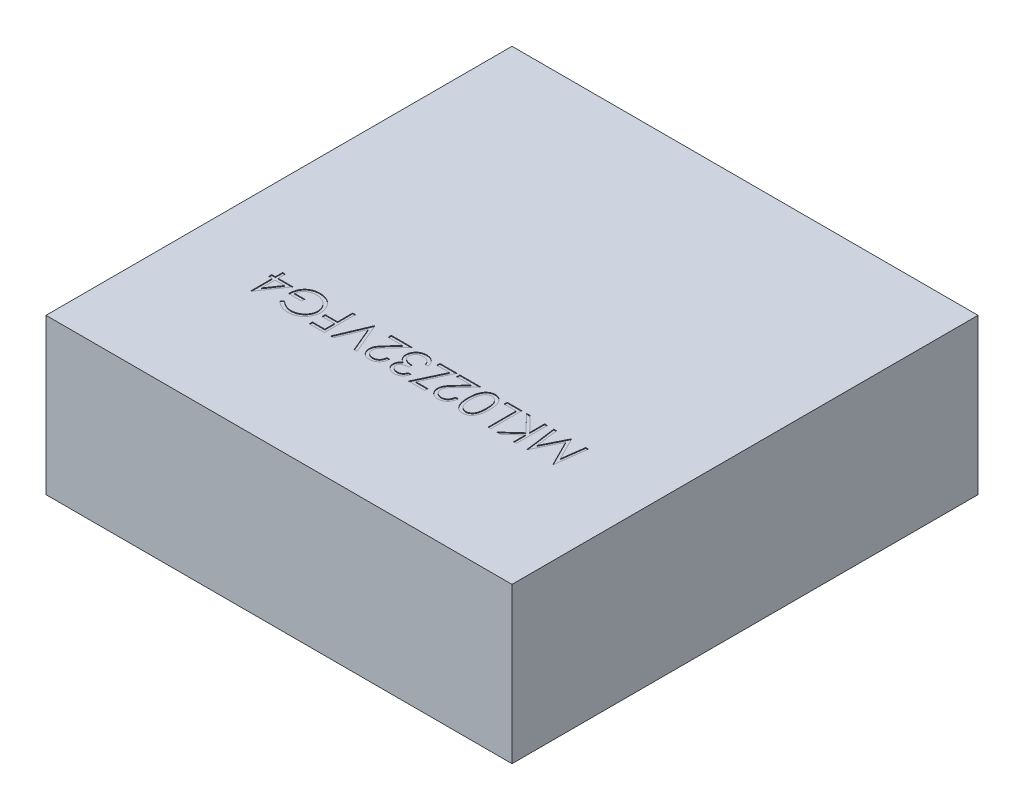
from build123d import *

# Parameters (mm, degrees)
BASES_W          = 3
BASES_H          = 3
BASE_DEPTH       = 1
PARTNUMBER_DEPTH = 0.005


with BuildPart() as part:
    # BaseS → Base (new body)
    with BuildSketch(Plane(origin=(0, 0, 0), x_dir=(1, 0, 0), z_dir=(0, 1, 0))):
        Rectangle(BASES_W, BASES_H)
    extrude(amount=BASE_DEPTH)

    # PartNumberS → PartNumber (cut)
    with BuildSketch(Plane(origin=(0, 1, 0), x_dir=(1, 0, 0), z_dir=(0, 1, 0))):
        Polygon((0.992307692, -0.5), (0.965905449, -0.7), (0.963341346, -0.7), (0.880769231, -0.535897436), (0.798397436, -0.7), (0.795793269, -0.7), (0.769230769, -0.5), (0.787259615, -0.5), (0.806410256, -0.643910256), (0.878605769, -0.5), (0.882652244, -0.5), (0.955128205, -0.644230769), (0.974238782, -0.5), align=None)
        Polygon((0.728205128, -0.7), (0.71025641, -0.7), (0.71025641, -0.623838141), (0.626883013, -0.7), (0.601282051, -0.7), (0.699559295, -0.61025641), (0.593589744, -0.5), (0.617508013, -0.5), (0.71025641, -0.596514423), (0.71025641, -0.5), (0.728205128, -0.5), align=None)
        Polygon((0.564102564, -0.7), (0.546153846, -0.7), (0.546153846, -0.520512821), (0.469230769, -0.520512821), (0.469230769, -0.5), (0.564102564, -0.5), align=None)
        with BuildLine():
            add(Edge.make_bspline(
                [(0.453846154, -0.599919872), (0.45382741, -0.603125437), (0.453791, -0.609352293), (0.453385947, -0.618425701), (0.45271307, -0.626937718), (0.451790935, -0.63488875), (0.450668765, -0.642280851), (0.449170735, -0.649094264), (0.447467153, -0.655360534), (0.445492704, -0.661100057), (0.443264911, -0.666390288), (0.440839812, -0.671328601), (0.438122833, -0.675909097), (0.4352634, -0.680199264), (0.432161436, -0.684155927), (0.42882773, -0.687761304), (0.425291645, -0.691071266), (0.421536448, -0.694031384), (0.417597932, -0.696610732), (0.413592604, -0.698948853), (0.409406222, -0.700798371), (0.405142046, -0.702379922), (0.400765722, -0.703632724), (0.396275342, -0.704504146), (0.391666876, -0.705049326), (0.388556562, -0.705101663), (0.386979167, -0.705128205)],
                knots=[0, 0, 0, 0, 1.64625301, 3.197870201, 4.6634513, 6.030635694, 7.308242971, 8.501545196, 9.611429483, 10.641742253, 11.616230371, 12.55791849, 13.464870342, 14.34944951, 15.20427819, 16.044004467, 16.869007726, 17.689551165, 18.496129964, 19.285613293, 20.0683943, 20.843080271, 21.620342827, 22.403213977, 23.190190624, 24, 24, 24, 24], degree=3))
            add(Edge.make_bspline(
                [(0.386979167, -0.705128205), (0.385387797, -0.705106134), (0.38222153, -0.705062219), (0.377557236, -0.704444098), (0.372974186, -0.703646272), (0.368541914, -0.702366689), (0.364176614, -0.700835502), (0.359986842, -0.698815126), (0.355824678, -0.696617809), (0.351879203, -0.693937268), (0.348032533, -0.690974829), (0.344426682, -0.687611703), (0.340969474, -0.683940966), (0.337791486, -0.679880749), (0.334756515, -0.675493306), (0.331979772, -0.67074186), (0.329403504, -0.66563694), (0.326979285, -0.66020221), (0.32485937, -0.654292502), (0.322974596, -0.647944676), (0.321429704, -0.641101249), (0.320152106, -0.633800343), (0.319160447, -0.62600579), (0.318438734, -0.617733383), (0.318057372, -0.608977945), (0.317985566, -0.60299178), (0.317948718, -0.599919872)],
                knots=[0, 0, 0, 0, 0.810910589, 1.61342667, 2.396193133, 3.181089899, 3.963115317, 4.752255436, 5.550715454, 6.36105385, 7.181178335, 8.024612154, 8.872680183, 9.750181803, 10.651284446, 11.591556747, 12.554036451, 13.566402641, 14.62422919, 15.753422176, 16.94128843, 18.199818041, 19.531985927, 20.947085226, 22.433341622, 24, 24, 24, 24], degree=3))
            add(Edge.make_bspline(
                [(0.317948718, -0.599919872), (0.317986423, -0.596861401), (0.318060053, -0.590888756), (0.318430055, -0.582172145), (0.319179794, -0.573944878), (0.32009359, -0.566195034), (0.321411105, -0.558932745), (0.322877893, -0.552119008), (0.324748864, -0.545817847), (0.326818495, -0.539958796), (0.329208983, -0.534547089), (0.331765848, -0.529463239), (0.334584042, -0.524738759), (0.337560777, -0.520323507), (0.34079893, -0.516298111), (0.344209352, -0.512586312), (0.347850186, -0.509217343), (0.351716657, -0.506219926), (0.355699424, -0.503519192), (0.3598624, -0.501243526), (0.364108132, -0.49925961), (0.368480783, -0.497664773), (0.372952469, -0.496404048), (0.377539293, -0.495545817), (0.382222154, -0.494940871), (0.385388005, -0.4948949), (0.386979167, -0.494871795)],
                knots=[0, 0, 0, 0, 1.561431216, 3.049195289, 4.452146966, 5.778046447, 7.031138842, 8.218704273, 9.334037798, 10.384210803, 11.388620812, 12.352076869, 13.287433199, 14.19507451, 15.06813243, 15.922055533, 16.766344942, 17.596869952, 18.417486629, 19.220035357, 20.016159057, 20.807716045, 21.59340902, 22.384936649, 23.188266813, 24, 24, 24, 24], degree=3))
            add(Edge.make_bspline(
                [(0.386979167, -0.494871795), (0.388556507, -0.494898572), (0.391666713, -0.494951373), (0.396275972, -0.495493155), (0.400759842, -0.49637662), (0.405127285, -0.497576361), (0.409387239, -0.49910116), (0.413497978, -0.501040647), (0.417513774, -0.503290158), (0.421416363, -0.505849366), (0.425131138, -0.508782275), (0.428680244, -0.512025516), (0.431970786, -0.515662669), (0.435051357, -0.519635684), (0.437934516, -0.52393665), (0.440639989, -0.528552213), (0.443057704, -0.533538633), (0.445336009, -0.538857583), (0.447344353, -0.544639279), (0.449098001, -0.550927022), (0.450576487, -0.557763701), (0.451754121, -0.565149643), (0.452718866, -0.573073415), (0.453385284, -0.581547642), (0.453790797, -0.590554174), (0.453827365, -0.596741003), (0.453846154, -0.599919872)],
                knots=[0, 0, 0, 0, 0.810976328, 1.599087026, 2.383086309, 3.159618043, 3.926613167, 4.707144544, 5.494386734, 6.292609454, 7.104690378, 7.92621526, 8.762510248, 9.62398222, 10.509836085, 11.424023232, 12.373226806, 13.358118208, 14.398657954, 15.5185989, 16.713620699, 17.994156382, 19.364120462, 20.818119981, 22.365111093, 24, 24, 24, 24], degree=3))
        make_face()
        with BuildLine():
            add(Edge.make_bspline(
                [(0.435897436, -0.6), (0.435890461, -0.597328656), (0.435876923, -0.592144103), (0.4355335, -0.58462337), (0.43505549, -0.577596997), (0.434454125, -0.571067726), (0.433553497, -0.565058375), (0.432531677, -0.559543965), (0.431306074, -0.554534693), (0.42984879, -0.549986815), (0.428188889, -0.54583583), (0.426379449, -0.541971444), (0.424419435, -0.538346652), (0.422263877, -0.534974532), (0.419881894, -0.531873918), (0.417326651, -0.529030085), (0.414583291, -0.526454611), (0.410786486, -0.523398046), (0.40579838, -0.520202297), (0.399481442, -0.517453649), (0.392987642, -0.515715134), (0.388578797, -0.515494661), (0.386378205, -0.515384615)],
                knots=[0, 0, 0, 0, 1.459193451, 2.832007961, 4.111736495, 5.306635028, 6.412683014, 7.430020708, 8.369596877, 9.227877302, 10.036669781, 10.810175692, 11.557788084, 12.286326232, 12.994037279, 13.69140682, 14.37267704, 15.047194847, 16.352618509, 17.594157723, 18.799169539, 20, 20, 20, 20], degree=3))
            add(Edge.make_bspline(
                [(0.386378205, -0.515384615), (0.384164977, -0.51548111), (0.379746373, -0.515673757), (0.373256993, -0.517355101), (0.367009194, -0.520088434), (0.362078497, -0.523211202), (0.35833772, -0.526204156), (0.355656526, -0.528752995), (0.3531959, -0.531607774), (0.35086205, -0.53468769), (0.348721536, -0.538051844), (0.346775069, -0.541683988), (0.344998878, -0.545594227), (0.343986933, -0.548323927), (0.343469551, -0.549719551)],
                knots=[0, 0, 0, 0, 1.353621445, 2.702441307, 4.075953605, 5.516772412, 6.261413105, 7.007624062, 7.778524365, 8.566925914, 9.372323995, 10.217594641, 11.088702136, 12, 12, 12, 12], degree=3))
            add(Edge.make_bspline(
                [(0.343469551, -0.549719551), (0.342866593, -0.551504108), (0.341642329, -0.555127523), (0.340064514, -0.560748303), (0.33882192, -0.566645604), (0.337704013, -0.572784182), (0.336940981, -0.579209308), (0.33632682, -0.585901101), (0.335965067, -0.592864607), (0.335920224, -0.59759575), (0.335897436, -0.6)],
                knots=[0, 0, 0, 0, 0.884706709, 1.796334032, 2.740027952, 3.714592787, 4.726048262, 5.777819803, 6.87074269, 8, 8, 8, 8], degree=3))
            add(Edge.make_bspline(
                [(0.335897436, -0.6), (0.335922569, -0.602404198), (0.33597174, -0.607107906), (0.336294799, -0.613989435), (0.336813929, -0.620536826), (0.337516559, -0.626756019), (0.338481122, -0.632635944), (0.339639466, -0.638185014), (0.34099749, -0.643401737), (0.342555191, -0.648299556), (0.344310674, -0.6528609), (0.346250042, -0.657095587), (0.348319312, -0.661026458), (0.350568319, -0.664640869), (0.352965243, -0.66795991), (0.35559615, -0.67090718), (0.358293925, -0.673626053), (0.362130733, -0.676674111), (0.367112943, -0.679806494), (0.373355261, -0.682610687), (0.379815791, -0.684270285), (0.384192311, -0.684500434), (0.386378205, -0.684615385)],
                knots=[0, 0, 0, 0, 1.313528337, 2.569860077, 3.762944266, 4.901481389, 5.988248151, 7.017139294, 7.997571128, 8.932104357, 9.823695246, 10.66607014, 11.475539426, 12.248954257, 12.990316782, 13.708962568, 14.405488541, 15.08007697, 16.381737273, 17.610043218, 18.806313575, 20, 20, 20, 20], degree=3))
            add(Edge.make_bspline(
                [(0.386378205, -0.684615385), (0.388590668, -0.684500298), (0.393019624, -0.684269916), (0.399547738, -0.682616543), (0.405827425, -0.679826438), (0.410799137, -0.676670238), (0.41458193, -0.673637891), (0.417273833, -0.671049847), (0.419814287, -0.668232609), (0.42218486, -0.665146054), (0.424327265, -0.661780364), (0.426311102, -0.658181849), (0.428106105, -0.654323203), (0.429772272, -0.650174513), (0.431214094, -0.645619162), (0.43251046, -0.640610889), (0.43351106, -0.635060616), (0.434399504, -0.629023046), (0.435071067, -0.622486012), (0.435530168, -0.615443005), (0.435877966, -0.607896056), (0.435890816, -0.602684734), (0.435897436, -0.6)],
                knots=[0, 0, 0, 0, 1.207779899, 2.417760083, 3.652287919, 4.947299644, 5.621638849, 6.297435916, 6.984320042, 7.691843698, 8.42018894, 9.161205785, 9.934506883, 10.743085206, 11.601138371, 12.542248028, 13.566483018, 14.679455109, 15.87477181, 17.154161492, 18.533899613, 20, 20, 20, 20], degree=3))
        make_face(mode=Mode.SUBTRACT)
        with BuildLine():
            Line((0.274358974, -0.638461538), (0.292307692, -0.638461538))
            add(Edge.make_bspline(
                [(0.292307692, -0.638461538), (0.292190732, -0.640842744), (0.291961025, -0.645519368), (0.290884841, -0.652337711), (0.289346382, -0.658855729), (0.287166027, -0.665017542), (0.284473479, -0.670896759), (0.28117702, -0.67641531), (0.277346927, -0.681627966), (0.272990226, -0.686436034), (0.268262803, -0.69083121), (0.263192984, -0.694666834), (0.257832876, -0.697870482), (0.252228972, -0.700563223), (0.246316459, -0.702581997), (0.240151855, -0.704080553), (0.233707297, -0.70498201), (0.229316444, -0.705078919), (0.227083333, -0.705128205)],
                knots=[0, 0, 0, 0, 1.100776268, 2.161895295, 3.184016182, 4.190939212, 5.176500551, 6.166955529, 7.155448256, 8.160289653, 9.16017456, 10.133824356, 11.091467644, 12.04088621, 13.000931625, 13.972173743, 14.968683325, 16, 16, 16, 16], degree=3))
            add(Edge.make_bspline(
                [(0.227083333, -0.705128205), (0.224890146, -0.705077281), (0.220580612, -0.704977218), (0.214293537, -0.70410498), (0.20829416, -0.702768352), (0.202650471, -0.70078768), (0.197304551, -0.698302371), (0.192322591, -0.695211563), (0.187584121, -0.691661503), (0.183321698, -0.687474033), (0.179406148, -0.683005992), (0.176031181, -0.678234162), (0.173124632, -0.673299943), (0.170745713, -0.668164791), (0.168942387, -0.662811984), (0.167606295, -0.657292841), (0.166842513, -0.651543668), (0.166725935, -0.647651753), (0.166666667, -0.645673077)],
                knots=[0, 0, 0, 0, 1.111674182, 2.184400057, 3.212814286, 4.223731311, 5.211378316, 6.196328225, 7.191884489, 8.207283132, 9.220262353, 10.201199469, 11.166417575, 12.120932471, 13.06540007, 14.026332106, 14.996573967, 16, 16, 16, 16], degree=3))
            add(Edge.make_bspline(
                [(0.166666667, -0.645673077), (0.166763426, -0.642887488), (0.166955247, -0.637365192), (0.168596046, -0.629250039), (0.171158789, -0.621387625), (0.174244079, -0.615059564), (0.177357402, -0.60996099), (0.180160152, -0.605761003), (0.183459894, -0.601239937), (0.187228437, -0.596379492), (0.191530681, -0.591243319), (0.196254853, -0.585726628), (0.201522957, -0.579931426), (0.205217164, -0.575970646), (0.20713141, -0.573918269)],
                knots=[0, 0, 0, 0, 1.184416499, 2.348048165, 3.509039915, 4.696071444, 5.333504901, 6.05069495, 6.844171097, 7.714965912, 8.667477798, 9.695072654, 10.805644396, 12, 12, 12, 12], degree=3))
            Line((0.20713141, -0.573918269), (0.257171474, -0.520512821))
            Line((0.257171474, -0.520512821), (0.164102564, -0.520512821))
            Line((0.164102564, -0.520512821), (0.164102564, -0.5))
            Line((0.164102564, -0.5), (0.3, -0.5))
            Line((0.3, -0.5), (0.222435897, -0.582772436))
            add(Edge.make_bspline(
                [(0.222435897, -0.582772436), (0.220547313, -0.58474366), (0.216919729, -0.588529979), (0.211791055, -0.594059562), (0.207177272, -0.59918341), (0.203075318, -0.603924227), (0.19948182, -0.608255137), (0.196408274, -0.61221008), (0.193841096, -0.615755116), (0.191120422, -0.619919677), (0.188526079, -0.625010393), (0.186245917, -0.631200221), (0.184865538, -0.637586255), (0.184699103, -0.64190044), (0.184615385, -0.644070513)],
                knots=[0, 0, 0, 0, 1.329530082, 2.553755191, 3.672934919, 4.687409497, 5.60679272, 6.413407421, 7.126401618, 7.737995624, 8.834647426, 9.90044882, 10.943907757, 12, 12, 12, 12], degree=3))
            add(Edge.make_bspline(
                [(0.184615385, -0.644070513), (0.18465134, -0.645435315), (0.1847222, -0.648125078), (0.185359423, -0.6520661), (0.186295629, -0.655882416), (0.187738613, -0.65952684), (0.189472304, -0.66307105), (0.191687223, -0.666407291), (0.194218293, -0.669649288), (0.197154211, -0.672685875), (0.200377303, -0.67546786), (0.203782799, -0.677932041), (0.207385633, -0.679991432), (0.211170791, -0.681679628), (0.215127673, -0.683003937), (0.219263944, -0.68392157), (0.223568174, -0.684497712), (0.226507231, -0.684575664), (0.228004808, -0.684615385)],
                knots=[0, 0, 0, 0, 0.991504627, 1.954065223, 2.895985987, 3.842598665, 4.797835564, 5.759220273, 6.74786863, 7.784730864, 8.824135544, 9.839918996, 10.835834653, 11.835434876, 12.84861661, 13.863796685, 14.911511676, 16, 16, 16, 16], degree=3))
            add(Edge.make_bspline(
                [(0.228004808, -0.684615385), (0.229569255, -0.68457615), (0.232641571, -0.6844991), (0.237142717, -0.683915127), (0.241466718, -0.683030728), (0.245546942, -0.681622773), (0.249468781, -0.679974945), (0.253132187, -0.677841298), (0.256640069, -0.675403277), (0.259921901, -0.672560698), (0.26291094, -0.669351856), (0.265630096, -0.665859087), (0.267934063, -0.662020473), (0.269979272, -0.657928121), (0.271543453, -0.6534696), (0.272880716, -0.648753945), (0.273852084, -0.643713878), (0.274187205, -0.640241397), (0.274358974, -0.638461538)],
                knots=[0, 0, 0, 0, 1.031072318, 2.024855787, 2.988461151, 3.935103592, 4.865765533, 5.788564469, 6.724086513, 7.67908574, 8.64457978, 9.611397706, 10.591395687, 11.591555111, 12.622101007, 13.700900657, 14.821571223, 16, 16, 16, 16], degree=3))
        make_face()
        Polygon((0.138461538, -0.679487179), (0.138461538, -0.7), (0.033333333, -0.7), (0.117227564, -0.520512821), (0.035897436, -0.520512821), (0.035897436, -0.5), (0.146153846, -0.5), (0.062259615, -0.679487179), align=None)
        with BuildLine():
            Line((-0.012820513, -0.653846154), (0.005128205, -0.653846154))
            add(Edge.make_bspline(
                [(0.005128205, -0.653846154), (0.004641945, -0.655859439), (0.003691346, -0.659795246), (0.001708628, -0.665418518), (-0.000451329, -0.670739862), (-0.003044993, -0.675659638), (-0.005874064, -0.680276718), (-0.009115363, -0.684486382), (-0.012619347, -0.688395694), (-0.016495058, -0.691865022), (-0.020559553, -0.695006607), (-0.024870103, -0.697685181), (-0.029339982, -0.699989419), (-0.034000161, -0.701887718), (-0.038864514, -0.703317748), (-0.043889064, -0.704355279), (-0.049086978, -0.705029057), (-0.052615412, -0.705094815), (-0.054407051, -0.705128205)],
                knots=[0, 0, 0, 0, 1.162005537, 2.271625781, 3.343758855, 4.383309926, 5.390229558, 6.379919256, 7.361854164, 8.333198761, 9.295911338, 10.242430842, 11.177959212, 12.116337295, 13.062827104, 14.020064771, 14.994644689, 16, 16, 16, 16], degree=3))
            add(Edge.make_bspline(
                [(-0.054407051, -0.705128205), (-0.057017494, -0.705049392), (-0.062181437, -0.704893485), (-0.069767897, -0.703469803), (-0.077083715, -0.701216938), (-0.084048815, -0.698104154), (-0.09051844, -0.694264879), (-0.096274793, -0.689695465), (-0.101239851, -0.684484076), (-0.105405244, -0.67872793), (-0.108666673, -0.672576186), (-0.111071608, -0.666244749), (-0.112535704, -0.659748636), (-0.11272545, -0.655362506), (-0.112820513, -0.653165064)],
                knots=[0, 0, 0, 0, 1.083050992, 2.142477498, 3.193116406, 4.255571735, 5.30263384, 6.308962982, 7.297363603, 8.282367274, 9.249857812, 10.179914175, 11.08814088, 12, 12, 12, 12], degree=3))
            add(Edge.make_bspline(
                [(-0.112820513, -0.653165064), (-0.112754022, -0.65105039), (-0.112623909, -0.646912301), (-0.111519126, -0.640871073), (-0.109659911, -0.635177267), (-0.107084496, -0.629806915), (-0.103750693, -0.624794067), (-0.099712254, -0.620127445), (-0.094940673, -0.61578635), (-0.091324734, -0.613299523), (-0.089463141, -0.612019231)],
                knots=[0, 0, 0, 0, 1.024540389, 2.004866551, 2.965041327, 3.920577974, 4.882998113, 5.874504559, 6.905732034, 8, 8, 8, 8], degree=3))
            add(Edge.make_bspline(
                [(-0.089463141, -0.612019231), (-0.091593382, -0.610995631), (-0.095820845, -0.608964297), (-0.101524926, -0.604917242), (-0.106781982, -0.600359254), (-0.109679284, -0.596762548), (-0.111137821, -0.594951923)],
                knots=[0, 0, 0, 0, 1.015663554, 2.015584519, 3.001021554, 4, 4, 4, 4], degree=3))
            add(Edge.make_bspline(
                [(-0.111137821, -0.594951923), (-0.112100575, -0.593634478), (-0.114010317, -0.591021161), (-0.11636091, -0.586817028), (-0.118517738, -0.582580215), (-0.120105101, -0.578144135), (-0.121474932, -0.573651284), (-0.122376235, -0.569005451), (-0.122954836, -0.564250776), (-0.123036083, -0.561032679), (-0.123076923, -0.559415064)],
                knots=[0, 0, 0, 0, 1.02516404, 2.033540309, 3.025129118, 4.011046665, 4.991655828, 5.976607087, 6.982917762, 8, 8, 8, 8], degree=3))
            add(Edge.make_bspline(
                [(-0.123076923, -0.559415064), (-0.122974139, -0.556614634), (-0.122769054, -0.551026954), (-0.120943858, -0.54276937), (-0.118096783, -0.534712452), (-0.114128911, -0.526970463), (-0.109197448, -0.519748905), (-0.103362856, -0.513268976), (-0.096618923, -0.507749819), (-0.089162002, -0.503097513), (-0.081051919, -0.499410613), (-0.072412013, -0.496753903), (-0.06329344, -0.49516025), (-0.05705766, -0.494969041), (-0.053886218, -0.494871795)],
                knots=[0, 0, 0, 0, 0.955619592, 1.906742024, 2.874954321, 3.868585453, 4.869520953, 5.854611167, 6.836527075, 7.836578462, 8.849204403, 9.870874567, 10.917152508, 12, 12, 12, 12], degree=3))
            add(Edge.make_bspline(
                [(-0.053886218, -0.494871795), (-0.051748107, -0.49492184), (-0.047541017, -0.495020311), (-0.041353757, -0.495681497), (-0.035460244, -0.496921931), (-0.029803249, -0.498481947), (-0.024468149, -0.500638844), (-0.019378204, -0.503210266), (-0.014555726, -0.506262151), (-0.010029353, -0.509799634), (-0.005803921, -0.513759317), (-0.001987081, -0.518206982), (0.001463397, -0.523059619), (0.00452559, -0.52836088), (0.007212384, -0.534095915), (0.00946596, -0.540287707), (0.01143361, -0.546888254), (0.012350224, -0.551486777), (0.012820513, -0.553846154)],
                knots=[0, 0, 0, 0, 1.048603596, 2.063302207, 3.045874044, 3.999447474, 4.937100059, 5.862643889, 6.7929026, 7.7308982, 8.676022965, 9.627908155, 10.600123445, 11.591992905, 12.626222643, 13.701663232, 14.820785756, 16, 16, 16, 16], degree=3))
            Line((0.012820513, -0.553846154), (-0.005128205, -0.553846154))
            add(Edge.make_bspline(
                [(-0.005128205, -0.553846154), (-0.005595822, -0.55230621), (-0.006505377, -0.549310886), (-0.008053622, -0.545000012), (-0.009817524, -0.541048123), (-0.011709784, -0.53742623), (-0.013697124, -0.534098664), (-0.015920834, -0.531153415), (-0.018216214, -0.528461117), (-0.019946462, -0.526944282), (-0.020793269, -0.526201923)],
                knots=[0, 0, 0, 0, 1.198163088, 2.33053128, 3.407730985, 4.417276592, 5.372219308, 6.28897303, 7.162600585, 8, 8, 8, 8], degree=3))
            add(Edge.make_bspline(
                [(-0.020793269, -0.526201923), (-0.021913199, -0.525338946), (-0.024149601, -0.523615655), (-0.027791622, -0.521410219), (-0.031635315, -0.519522419), (-0.035712732, -0.517987935), (-0.04002442, -0.516836097), (-0.044552889, -0.516007058), (-0.04930557, -0.515459763), (-0.052549182, -0.51541003), (-0.054206731, -0.515384615)],
                knots=[0, 0, 0, 0, 0.946083416, 1.889246487, 2.84504177, 3.809995578, 4.801312957, 5.829064617, 6.89060985, 8, 8, 8, 8], degree=3))
            add(Edge.make_bspline(
                [(-0.054206731, -0.515384615), (-0.056078385, -0.515419753), (-0.059738243, -0.515488461), (-0.065078166, -0.516122158), (-0.070159857, -0.517041039), (-0.074931455, -0.518478347), (-0.079457891, -0.520202635), (-0.083638121, -0.522460045), (-0.08759504, -0.525009425), (-0.091212727, -0.527974844), (-0.094474249, -0.531180141), (-0.097292565, -0.534580675), (-0.099733548, -0.538071008), (-0.101695691, -0.541732562), (-0.103247839, -0.545529421), (-0.104303838, -0.549475795), (-0.105038259, -0.553538455), (-0.105098059, -0.556300116), (-0.105128205, -0.557692308)],
                knots=[0, 0, 0, 0, 1.216990249, 2.379719373, 3.493992396, 4.571561497, 5.616923107, 6.638958652, 7.655775068, 8.674704564, 9.676001865, 10.625896028, 11.54399481, 12.441854662, 13.322657739, 14.20572845, 15.095482574, 16, 16, 16, 16], degree=3))
            add(Edge.make_bspline(
                [(-0.105128205, -0.557692308), (-0.105040577, -0.559555696), (-0.104865756, -0.5632732), (-0.10353657, -0.568744529), (-0.101330697, -0.574018171), (-0.098302612, -0.579025064), (-0.094528157, -0.583611196), (-0.09018575, -0.58771628), (-0.085182738, -0.591134393), (-0.0805519, -0.593489428), (-0.076439391, -0.595058495), (-0.0729271, -0.596158774), (-0.068991468, -0.597038296), (-0.064679786, -0.597889066), (-0.059973855, -0.598602295), (-0.05486944, -0.599199653), (-0.049364486, -0.599676883), (-0.04555357, -0.599890117), (-0.043589744, -0.6)],
                knots=[0, 0, 0, 0, 1.070440979, 2.135555593, 3.216243406, 4.345886539, 5.486149072, 6.621334998, 7.769144672, 8.957074012, 9.598644492, 10.297969361, 11.070758978, 11.915404831, 12.824182859, 13.805940418, 14.869366021, 16, 16, 16, 16], degree=3))
            Line((-0.043589744, -0.6), (-0.043589744, -0.620512821))
            add(Edge.make_bspline(
                [(-0.043589744, -0.620512821), (-0.046063134, -0.620561043), (-0.050906203, -0.620655467), (-0.058000575, -0.62156233), (-0.064763729, -0.623034295), (-0.071093937, -0.625089351), (-0.076833851, -0.627591218), (-0.081861201, -0.630392354), (-0.085995127, -0.633623909), (-0.089309668, -0.637133123), (-0.0917681, -0.640920736), (-0.093582769, -0.644850479), (-0.094656107, -0.648995461), (-0.094799646, -0.651823627), (-0.094871795, -0.653245192)],
                knots=[0, 0, 0, 0, 1.321816535, 2.58820849, 3.816448615, 5.017641336, 6.139869627, 7.160068286, 8.085608132, 8.934319198, 9.728416342, 10.48890201, 11.240453369, 12, 12, 12, 12], degree=3))
            add(Edge.make_bspline(
                [(-0.094871795, -0.653245192), (-0.094848635, -0.654289811), (-0.09480256, -0.656368031), (-0.094198289, -0.659413745), (-0.093332212, -0.662366392), (-0.092073978, -0.665191473), (-0.090446698, -0.667897968), (-0.088477933, -0.670495763), (-0.086162694, -0.673009663), (-0.083516016, -0.675384225), (-0.080562255, -0.677521373), (-0.077419965, -0.679426611), (-0.074076894, -0.681028645), (-0.070554829, -0.682356622), (-0.06683473, -0.683353822), (-0.062936169, -0.684070288), (-0.058851131, -0.684518117), (-0.056064178, -0.684582603), (-0.054647436, -0.684615385)],
                knots=[0, 0, 0, 0, 0.884246871, 1.759167212, 2.622361933, 3.489113179, 4.372562419, 5.294145153, 6.247651513, 7.265905295, 8.30305477, 9.334068495, 10.37719476, 11.441246459, 12.52060732, 13.637552802, 14.799054011, 16, 16, 16, 16], degree=3))
            add(Edge.make_bspline(
                [(-0.054647436, -0.684615385), (-0.052370122, -0.684536032), (-0.047922, -0.684381039), (-0.041510767, -0.683018718), (-0.035556811, -0.680860261), (-0.031021098, -0.678253931), (-0.027666084, -0.67569), (-0.025222657, -0.67348425), (-0.022866943, -0.670983381), (-0.020691383, -0.668118798), (-0.018565612, -0.664989002), (-0.016509928, -0.661576754), (-0.014590359, -0.657833407), (-0.013421887, -0.655200978), (-0.012820513, -0.653846154)],
                knots=[0, 0, 0, 0, 1.4727372, 2.876598283, 4.222346151, 5.558423782, 6.24313385, 6.953189256, 7.68715613, 8.463578749, 9.278833271, 10.135787152, 11.040551781, 12, 12, 12, 12], degree=3))
        make_face()
        with BuildLine():
            Line((-0.166666667, -0.638461538), (-0.148717949, -0.638461538))
            add(Edge.make_bspline(
                [(-0.148717949, -0.638461538), (-0.148834909, -0.640842744), (-0.149064616, -0.645519368), (-0.1501408, -0.652337711), (-0.151679259, -0.658855729), (-0.153859614, -0.665017542), (-0.156552162, -0.670896759), (-0.159848621, -0.67641531), (-0.163678714, -0.681627966), (-0.168035415, -0.686436034), (-0.172762838, -0.69083121), (-0.177832657, -0.694666834), (-0.183192765, -0.697870482), (-0.18879667, -0.700563223), (-0.194709182, -0.702581997), (-0.200873786, -0.704080553), (-0.207318344, -0.70498201), (-0.211709197, -0.705078919), (-0.213942308, -0.705128205)],
                knots=[0, 0, 0, 0, 1.100776268, 2.161895295, 3.184016182, 4.190939212, 5.176500551, 6.166955529, 7.155448256, 8.160289653, 9.16017456, 10.133824356, 11.091467644, 12.04088621, 13.000931625, 13.972173743, 14.968683325, 16, 16, 16, 16], degree=3))
            add(Edge.make_bspline(
                [(-0.213942308, -0.705128205), (-0.216135495, -0.705077281), (-0.220445029, -0.704977218), (-0.226732104, -0.70410498), (-0.232731481, -0.702768352), (-0.23837517, -0.70078768), (-0.24372109, -0.698302371), (-0.24870305, -0.695211563), (-0.25344152, -0.691661503), (-0.257703943, -0.687474033), (-0.261619493, -0.683005992), (-0.26499446, -0.678234162), (-0.267901009, -0.673299943), (-0.270279928, -0.668164791), (-0.272083254, -0.662811984), (-0.273419346, -0.657292841), (-0.274183128, -0.651543668), (-0.274299706, -0.647651753), (-0.274358974, -0.645673077)],
                knots=[0, 0, 0, 0, 1.111674182, 2.184400057, 3.212814286, 4.223731311, 5.211378316, 6.196328225, 7.191884489, 8.207283132, 9.220262353, 10.201199469, 11.166417575, 12.120932471, 13.06540007, 14.026332106, 14.996573967, 16, 16, 16, 16], degree=3))
            add(Edge.make_bspline(
                [(-0.274358974, -0.645673077), (-0.274262215, -0.642887488), (-0.274070394, -0.637365192), (-0.272429595, -0.629250039), (-0.269866852, -0.621387625), (-0.266781563, -0.615059564), (-0.263668239, -0.60996099), (-0.260865489, -0.605761003), (-0.257565747, -0.601239937), (-0.253797204, -0.596379492), (-0.24949496, -0.591243319), (-0.244770788, -0.585726628), (-0.239502684, -0.579931426), (-0.235808477, -0.575970646), (-0.233894231, -0.573918269)],
                knots=[0, 0, 0, 0, 1.184416499, 2.348048165, 3.509039915, 4.696071444, 5.333504901, 6.05069495, 6.844171097, 7.714965912, 8.667477798, 9.695072654, 10.805644396, 12, 12, 12, 12], degree=3))
            Line((-0.233894231, -0.573918269), (-0.183854167, -0.520512821))
            Line((-0.183854167, -0.520512821), (-0.276923077, -0.520512821))
            Line((-0.276923077, -0.520512821), (-0.276923077, -0.5))
            Line((-0.276923077, -0.5), (-0.141025641, -0.5))
            Line((-0.141025641, -0.5), (-0.218589744, -0.582772436))
            add(Edge.make_bspline(
                [(-0.218589744, -0.582772436), (-0.220478328, -0.58474366), (-0.224105912, -0.588529979), (-0.229234586, -0.594059562), (-0.233848369, -0.59918341), (-0.237950323, -0.603924227), (-0.241543821, -0.608255137), (-0.244617367, -0.61221008), (-0.247184545, -0.615755116), (-0.249905219, -0.619919677), (-0.252499562, -0.625010393), (-0.254779724, -0.631200221), (-0.256160103, -0.637586255), (-0.256326538, -0.64190044), (-0.256410256, -0.644070513)],
                knots=[0, 0, 0, 0, 1.329530082, 2.553755191, 3.672934919, 4.687409497, 5.60679272, 6.413407421, 7.126401618, 7.737995624, 8.834647426, 9.90044882, 10.943907757, 12, 12, 12, 12], degree=3))
            add(Edge.make_bspline(
                [(-0.256410256, -0.644070513), (-0.256374301, -0.645435315), (-0.256303441, -0.648125078), (-0.255666218, -0.6520661), (-0.254730012, -0.655882416), (-0.253287029, -0.65952684), (-0.251553337, -0.66307105), (-0.249338418, -0.666407291), (-0.246807348, -0.669649288), (-0.24387143, -0.672685875), (-0.240648338, -0.67546786), (-0.237242842, -0.677932041), (-0.233640008, -0.679991432), (-0.22985485, -0.681679628), (-0.225897968, -0.683003937), (-0.221761697, -0.68392157), (-0.217457467, -0.684497712), (-0.21451841, -0.684575664), (-0.213020833, -0.684615385)],
                knots=[0, 0, 0, 0, 0.991504627, 1.954065223, 2.895985987, 3.842598665, 4.797835564, 5.759220273, 6.74786863, 7.784730864, 8.824135544, 9.839918996, 10.835834653, 11.835434876, 12.84861661, 13.863796685, 14.911511676, 16, 16, 16, 16], degree=3))
            add(Edge.make_bspline(
                [(-0.213020833, -0.684615385), (-0.211456386, -0.68457615), (-0.20838407, -0.6844991), (-0.203882924, -0.683915127), (-0.199558923, -0.683030728), (-0.195478699, -0.681622773), (-0.19155686, -0.679974945), (-0.187893454, -0.677841298), (-0.184385572, -0.675403277), (-0.18110374, -0.672560698), (-0.178114701, -0.669351856), (-0.175395545, -0.665859087), (-0.173091578, -0.662020473), (-0.171046369, -0.657928121), (-0.169482188, -0.6534696), (-0.168144925, -0.648753945), (-0.167173557, -0.643713878), (-0.166838437, -0.640241397), (-0.166666667, -0.638461538)],
                knots=[0, 0, 0, 0, 1.031072318, 2.024855787, 2.988461151, 3.935103592, 4.865765533, 5.788564469, 6.724086513, 7.67908574, 8.64457978, 9.611397706, 10.591395687, 11.591555111, 12.622101007, 13.700900657, 14.821571223, 16, 16, 16, 16], degree=3))
        make_face()
        Polygon((-0.297435897, -0.7), (-0.316666667, -0.7), (-0.383333333, -0.542387821), (-0.45, -0.7), (-0.469230769, -0.7), (-0.384615385, -0.5), (-0.382051282, -0.5), align=None)
        Polygon((-0.507692308, -0.7), (-0.605128205, -0.7), (-0.605128205, -0.679487179), (-0.525641026, -0.679487179), (-0.525641026, -0.617948718), (-0.605128205, -0.617948718), (-0.605128205, -0.597435897), (-0.525641026, -0.597435897), (-0.525641026, -0.5), (-0.507692308, -0.5), align=None)
        with BuildLine():
            Line((-0.828205128, -0.665865385), (-0.812820513, -0.651282051))
            add(Edge.make_bspline(
                [(-0.812820513, -0.651282051), (-0.810020275, -0.653897361), (-0.804501438, -0.659051734), (-0.795546874, -0.665814039), (-0.786191253, -0.671561805), (-0.776510638, -0.676284033), (-0.766691706, -0.679954787), (-0.756930493, -0.682608935), (-0.747295434, -0.684315877), (-0.740898825, -0.684516382), (-0.737740385, -0.684615385)],
                knots=[0, 0, 0, 0, 1.091957225, 2.152079168, 3.193085318, 4.218301889, 5.218403563, 6.17723952, 7.099979378, 8, 8, 8, 8], degree=3))
            add(Edge.make_bspline(
                [(-0.737740385, -0.684615385), (-0.735802413, -0.684591715), (-0.731931495, -0.684544437), (-0.726181508, -0.68394243), (-0.720492593, -0.683073917), (-0.71488437, -0.681830197), (-0.70933454, -0.680214815), (-0.703855449, -0.678264482), (-0.698457673, -0.675916697), (-0.693169607, -0.673240008), (-0.688016869, -0.670317961), (-0.683170691, -0.667059014), (-0.678610865, -0.663563454), (-0.674369635, -0.659785436), (-0.670388906, -0.655787843), (-0.666741547, -0.651513873), (-0.663347796, -0.647026785), (-0.660334591, -0.642262259), (-0.657611098, -0.637355671), (-0.655252785, -0.632346134), (-0.65322214, -0.627268979), (-0.651599532, -0.622121344), (-0.650295017, -0.616906515), (-0.649371664, -0.61163264), (-0.648853041, -0.606273736), (-0.648763142, -0.602685345), (-0.648717949, -0.60088141)],
                knots=[0, 0, 0, 0, 1.028307134, 2.053947307, 3.065600992, 4.082111276, 5.100671203, 6.132125737, 7.167228006, 8.222953114, 9.277225349, 10.309459149, 11.320441984, 12.324791754, 13.322338422, 14.312705492, 15.305176196, 16.306142747, 17.302479595, 18.282363326, 19.243345101, 20.20291386, 21.145121196, 22.094978082, 23.042318507, 24, 24, 24, 24], degree=3))
            add(Edge.make_bspline(
                [(-0.648717949, -0.60088141), (-0.648761546, -0.599037476), (-0.64884862, -0.595354642), (-0.649394472, -0.589856161), (-0.65044167, -0.584450551), (-0.65172081, -0.579086816), (-0.653531397, -0.573833418), (-0.655636148, -0.568613422), (-0.658174006, -0.563475342), (-0.661096406, -0.558454992), (-0.664325972, -0.553569413), (-0.667877347, -0.548928661), (-0.671757239, -0.544586973), (-0.675894313, -0.540480871), (-0.680326315, -0.536636284), (-0.68509623, -0.53309955), (-0.690137293, -0.52981598), (-0.695451738, -0.526821646), (-0.700983394, -0.524146939), (-0.70665519, -0.521768413), (-0.712485356, -0.519809599), (-0.718443222, -0.518213134), (-0.724521695, -0.516904546), (-0.730751627, -0.51606269), (-0.73708721, -0.515451785), (-0.741357989, -0.515407119), (-0.743509615, -0.515384615)],
                knots=[0, 0, 0, 0, 0.935896426, 1.86923723, 2.799743935, 3.728471844, 4.66505513, 5.616527375, 6.583419551, 7.570341864, 8.562833498, 9.553750335, 10.533080376, 11.5155245, 12.510142773, 13.507781369, 14.526649666, 15.561487327, 16.601173999, 17.643331812, 18.680652164, 19.71969803, 20.772446191, 21.833473655, 22.9085001, 24, 24, 24, 24], degree=3))
            add(Edge.make_bspline(
                [(-0.743509615, -0.515384615), (-0.746102674, -0.515438797), (-0.751194567, -0.515545192), (-0.758679357, -0.516374099), (-0.76586865, -0.51766704), (-0.772739038, -0.519566416), (-0.779315468, -0.521970551), (-0.785573641, -0.524943629), (-0.791530996, -0.52845427), (-0.797161156, -0.532431751), (-0.802332451, -0.53686225), (-0.807032866, -0.541604398), (-0.811124662, -0.546696032), (-0.814634526, -0.552136044), (-0.817655509, -0.557844333), (-0.820065306, -0.563918737), (-0.821929169, -0.570291408), (-0.822691652, -0.574697001), (-0.823076923, -0.576923077)],
                knots=[0, 0, 0, 0, 1.130234505, 2.219399076, 3.279128566, 4.311639422, 5.322903917, 6.328167287, 7.327698761, 8.334124803, 9.329374007, 10.292761544, 11.24113083, 12.171311216, 13.111441694, 14.052040787, 15.015727358, 16, 16, 16, 16], degree=3))
            Line((-0.823076923, -0.576923077), (-0.756410256, -0.576923077))
            Line((-0.756410256, -0.576923077), (-0.756410256, -0.597435897))
            Line((-0.756410256, -0.597435897), (-0.841025641, -0.597435897))
            add(Edge.make_bspline(
                [(-0.841025641, -0.597435897), (-0.840928164, -0.593612612), (-0.840737384, -0.586129753), (-0.83939916, -0.575217166), (-0.837238216, -0.564910212), (-0.834286199, -0.555198036), (-0.830464754, -0.546094403), (-0.825814895, -0.537590067), (-0.820262203, -0.529739971), (-0.814004463, -0.522480028), (-0.806981608, -0.516004073), (-0.799383402, -0.510312305), (-0.791197289, -0.50551787), (-0.782431014, -0.501617261), (-0.773113275, -0.498573033), (-0.763222511, -0.496414657), (-0.752772134, -0.495121516), (-0.745610038, -0.494956294), (-0.741947115, -0.494871795)],
                knots=[0, 0, 0, 0, 1.140356446, 2.231883559, 3.274166699, 4.278491846, 5.25512956, 6.21435461, 7.1637429, 8.11826594, 9.068280886, 10.0076534, 10.945064095, 11.891975133, 12.864533718, 13.863980011, 14.907571808, 16, 16, 16, 16], degree=3))
            add(Edge.make_bspline(
                [(-0.741947115, -0.494871795), (-0.739689393, -0.494904316), (-0.735236438, -0.494968458), (-0.728659813, -0.495424307), (-0.722264521, -0.496126054), (-0.716051492, -0.497185775), (-0.709997872, -0.498483756), (-0.704133896, -0.500145854), (-0.698437225, -0.50206978), (-0.692899054, -0.504258104), (-0.687569652, -0.506793627), (-0.682425279, -0.509611321), (-0.677437501, -0.512696656), (-0.672640291, -0.51610299), (-0.668008656, -0.519804844), (-0.663572459, -0.52380964), (-0.659306866, -0.528105132), (-0.656634839, -0.531155361), (-0.655288462, -0.532692308)],
                knots=[0, 0, 0, 0, 1.107784379, 2.184907829, 3.233506516, 4.263428166, 5.276301166, 6.270063455, 7.25232949, 8.225834625, 9.190232166, 10.146266622, 11.1027726, 12.066435141, 13.031522626, 14.010570082, 14.99756817, 16, 16, 16, 16], degree=3))
            add(Edge.make_bspline(
                [(-0.655288462, -0.532692308), (-0.65333498, -0.535130631), (-0.649460442, -0.539966803), (-0.644473119, -0.547715371), (-0.64022161, -0.555738335), (-0.63677202, -0.564058028), (-0.634078415, -0.572666669), (-0.632146629, -0.581553257), (-0.631014784, -0.590729236), (-0.630851725, -0.596938679), (-0.630769231, -0.600080128)],
                knots=[0, 0, 0, 0, 1.023165419, 2.029347347, 3.013907458, 3.994755782, 4.975994455, 5.96558838, 6.970761222, 8, 8, 8, 8], degree=3))
            add(Edge.make_bspline(
                [(-0.630769231, -0.600080128), (-0.630799727, -0.602432461), (-0.630860331, -0.607107229), (-0.631592006, -0.614048011), (-0.63264805, -0.620863832), (-0.63417769, -0.627561004), (-0.636190312, -0.634109795), (-0.638607394, -0.640560525), (-0.641438484, -0.64688741), (-0.644742263, -0.653034374), (-0.648338388, -0.658999315), (-0.652382174, -0.664594485), (-0.656648981, -0.669928071), (-0.661343228, -0.67484907), (-0.666289009, -0.679514686), (-0.671609344, -0.68380195), (-0.677216946, -0.687783194), (-0.683157094, -0.691380513), (-0.689335565, -0.694612979), (-0.695739061, -0.697446579), (-0.702365221, -0.699788502), (-0.70916451, -0.70177557), (-0.716188366, -0.703245008), (-0.723385826, -0.70431065), (-0.730794403, -0.705039827), (-0.735802177, -0.70509847), (-0.738341346, -0.705128205)],
                knots=[0, 0, 0, 0, 1.009025537, 2.005226976, 2.991671811, 3.967589759, 4.950148279, 5.929425679, 6.922109907, 7.921964004, 8.922507644, 9.908469609, 10.882248289, 11.851158214, 12.824245259, 13.798023939, 14.780666017, 15.773333703, 16.775582742, 17.771174102, 18.775387309, 19.789283316, 20.80873549, 21.851817535, 22.910773411, 24, 24, 24, 24], degree=3))
            add(Edge.make_bspline(
                [(-0.738341346, -0.705128205), (-0.740412118, -0.705095174), (-0.744518215, -0.705029677), (-0.750628036, -0.704573344), (-0.756631389, -0.703858075), (-0.76255839, -0.702857891), (-0.768386473, -0.70153481), (-0.774133293, -0.699922357), (-0.779787982, -0.698055448), (-0.785343812, -0.695827193), (-0.790838558, -0.693298502), (-0.796302658, -0.690451996), (-0.801717473, -0.687239146), (-0.807092386, -0.68365037), (-0.812461292, -0.679747318), (-0.817739272, -0.675418357), (-0.823053726, -0.670834199), (-0.826470972, -0.667538075), (-0.828205128, -0.665865385)],
                knots=[0, 0, 0, 0, 0.985875312, 1.954874891, 2.915472732, 3.863573565, 4.815313299, 5.759461513, 6.704487138, 7.649063459, 8.607849844, 9.583336382, 10.581114205, 11.603942397, 12.659508253, 13.739925933, 14.853076422, 16, 16, 16, 16], degree=3))
        make_face()
        Polygon((-0.973277244, -0.705128205), (-0.976923077, -0.705128205), (-0.976923077, -0.566666667), (-1, -0.566666667), (-1, -0.546153846), (-0.976923077, -0.546153846), (-0.976923077, -0.5), (-0.958974359, -0.5), (-0.958974359, -0.546153846), (-0.864102564, -0.546153846), align=None)
        Polygon((-0.958974359, -0.566666667), (-0.958974359, -0.653525641), (-0.899358974, -0.566666667), align=None, mode=Mode.SUBTRACT)
    extrude(amount=-PARTNUMBER_DEPTH, mode=Mode.SUBTRACT)


solid = part.part
